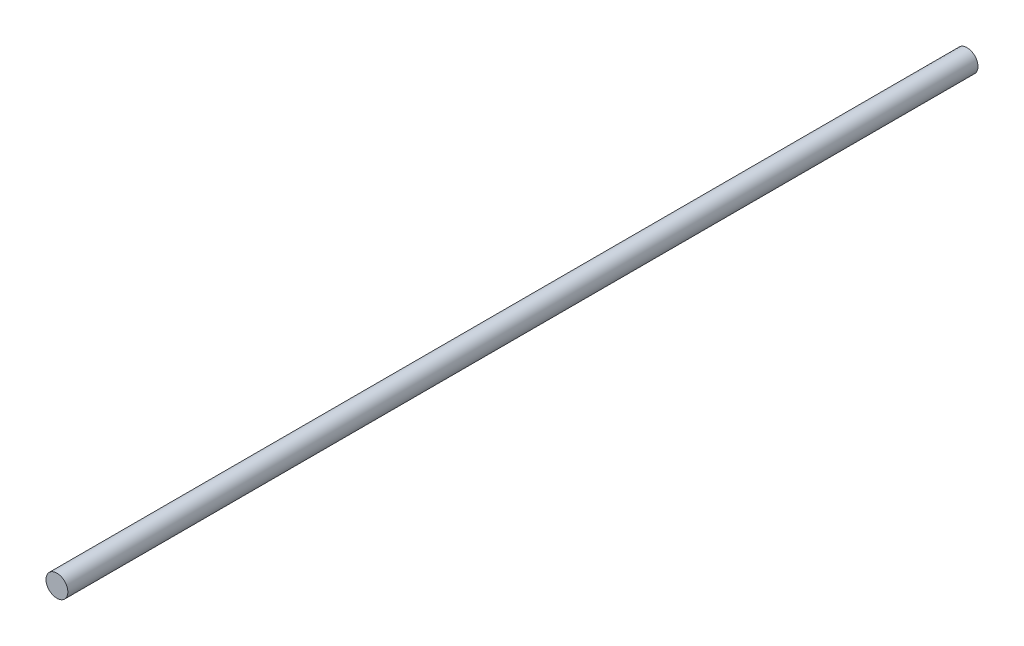
from build123d import *

# Parameters (mm, degrees)
ESQUISSE1_R        = 3
BOSS_EXTRU_1_DEPTH = 250


with BuildPart() as part:
    # Esquisse1 → Boss.-Extru.1 (new body)
    with BuildSketch(Plane.XY):
        Circle(ESQUISSE1_R)
    extrude(amount=BOSS_EXTRU_1_DEPTH)


solid = part.part
